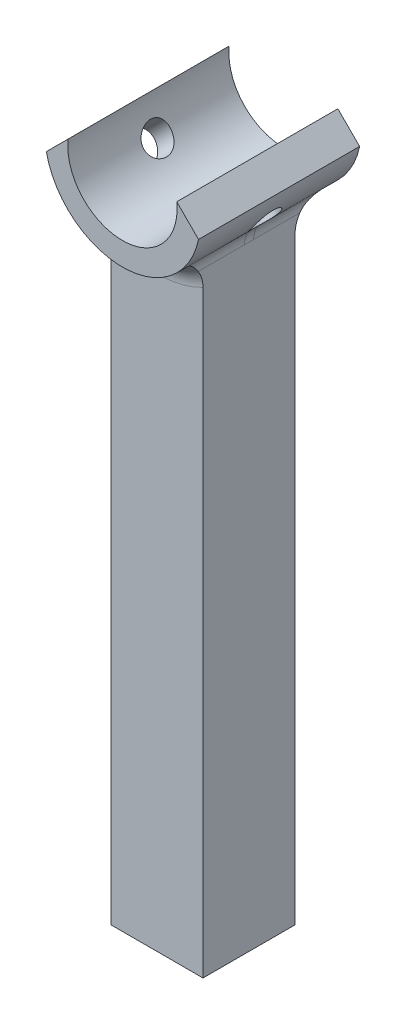
from build123d import *

# Parameters (mm, degrees)
SKETCH1_W           = 8
SKETCH1_H           = 8
BOSS_EXTRUDE1_DEPTH = 55
BOSS_EXTRUDE2_START = 4
BOSS_EXTRUDE2_DEPTH = 14
SKETCH4_R           = 1.25
CUT_EXTRUDE1_DEPTH  = 17.337084372
FILLET1_R           = 2


with BuildPart() as part:
    # Sketch1 → Boss-Extrude1 (new body)
    with BuildSketch(Plane(origin=(0, 0, 0), x_dir=(1, 0, 0), z_dir=(0, 1, 0))):
        with Locations((0, -11)):
            Rectangle(SKETCH1_W, SKETCH1_H)
    extrude(amount=-BOSS_EXTRUDE1_DEPTH)

    # Sketch2 → Boss-Extrude2 (add)
    with BuildSketch(Plane.XY.offset(BOSS_EXTRUDE2_START)):
        with BuildLine():
            Line((-4.720381827, 5.279618173), (-6.61130468, 3.38869532))
            ThreePointArc((-6.61130468, 3.38869532), (0, -2), (6.61130468, 3.38869532))
            Line((6.61130468, 3.38869532), (4.720381827, 5.279618173))
            ThreePointArc((4.720381827, 5.279618173), (4.742589676, 5.015222852), (4.75, 4.75))
            ThreePointArc((4.75, 4.75), (-0.265222852, 0.007410324), (-4.720381827, 5.279618173))
        make_face()
    extrude(amount=BOSS_EXTRUDE2_DEPTH)

    # Sketch4 → Cut-Extrude1 (cut, through all)
    with BuildSketch(Plane(origin=(-5.606601718, -5.606601718, 0), x_dir=(0.707106781, -0.707106781, 0), z_dir=(-0.707106781, -0.707106781, 0))):
        with Locations((-4.342545211, 11)):
            Circle(SKETCH4_R)
    cut_extrude1 = extrude(amount=-CUT_EXTRUDE1_DEPTH, mode=Mode.SUBTRACT)

    # Mirror1: Cut-Extrude1 across plane
    add(cut_extrude1.mirror(Plane(origin=(0, 0, 0), x_dir=(0, 0, 1), z_dir=(1, 0, 0))), mode=Mode.SUBTRACT)

    # Fillet1
    fillet1_edges = [part.edges().sort_by_distance(p)[0] for p in [
        (4, -0.687140793, 11),
        (-4, -0.687140793, 11),
        (0, -2, 15),
        (0, -2, 7),
    ]]
    fillet(fillet1_edges, radius=FILLET1_R)


solid = part.part
